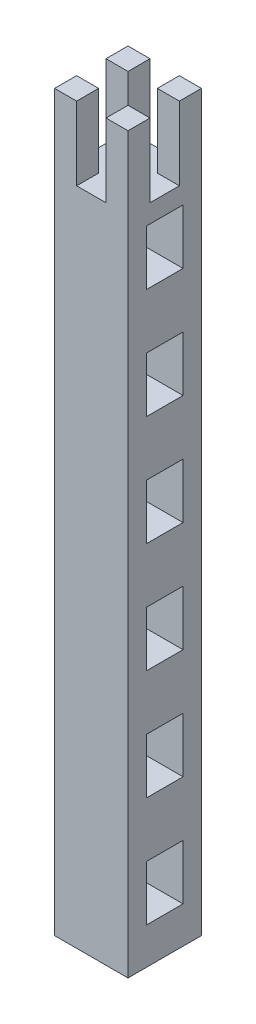
from build123d import *

# Parameters (mm, degrees)
SKETCH4_W           = 20
SKETCH4_H           = 20
BOSS_EXTRUDE2_DEPTH = 200
CUT_EXTRUDE3_DEPTH  = 20
SKETCH6_W           = 10
SKETCH6_H           = 15
CUT_EXTRUDE5_DEPTH  = 21


with BuildPart() as part:
    # Sketch4 → Boss-Extrude2 (new body)
    with BuildSketch(Plane(origin=(0, 0, 0), x_dir=(1, 0, 0), z_dir=(0, 1, 0))):
        with Locations((10, 10)):
            Rectangle(SKETCH4_W, SKETCH4_H)
    extrude(amount=BOSS_EXTRUDE2_DEPTH)

    # Sketch5 → Cut-Extrude3 (cut)
    with BuildSketch(Plane(origin=(0, 200, 0), x_dir=(1, 0, 0), z_dir=(0, 1, 0))):
        Polygon((14, 20), (6, 20), (6, 14), (0, 14), (0, 6), (6, 6), (6, 0), (14, 0), (14, 6), (20, 6), (20, 14), (14, 14), align=None)
    extrude(amount=-CUT_EXTRUDE3_DEPTH, mode=Mode.SUBTRACT)

    # Sketch6 → Cut-Extrude5 (cut, through all)
    with BuildSketch(Plane(origin=(20, 0, 0), x_dir=(0, 0, -1), z_dir=(1, 0, 0))):
        with Locations((10, 17.5)):
            Rectangle(SKETCH6_W, SKETCH6_H)
        with Locations((10, 47.5)):
            Rectangle(SKETCH6_W, SKETCH6_H)
        with Locations((10, 77.5)):
            Rectangle(SKETCH6_W, SKETCH6_H)
        with Locations((10, 107.5)):
            Rectangle(SKETCH6_W, SKETCH6_H)
        with Locations((10, 137.5)):
            Rectangle(SKETCH6_W, SKETCH6_H)
        with Locations((10, 167.5)):
            Rectangle(SKETCH6_W, SKETCH6_H)
    extrude(amount=-CUT_EXTRUDE5_DEPTH, mode=Mode.SUBTRACT)


solid = part.part
